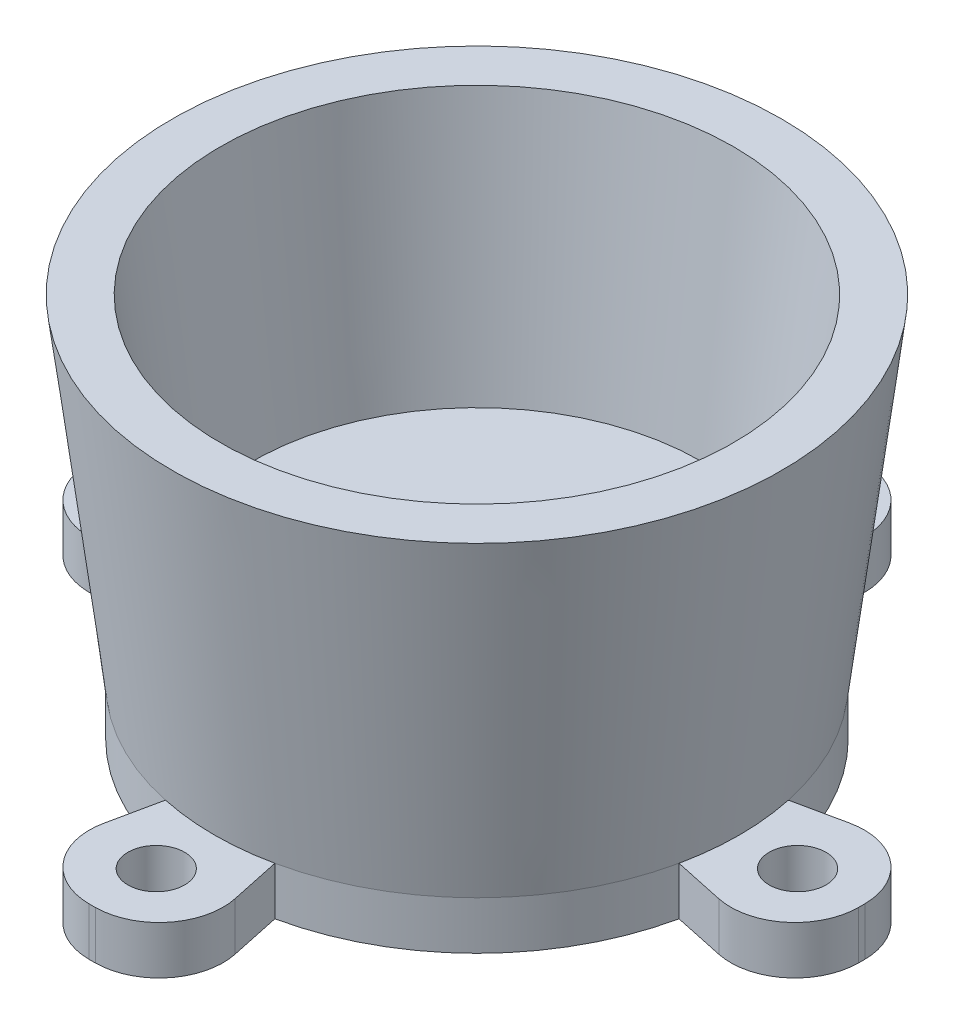
from build123d import *

# Parameters (mm, degrees)
SKETCH2_R          = 2.2479
CUT_EXTRUDE1_DEPTH = 4.81
FILLET1_R          = 5.08


with BuildPart() as part:
    # Sketch1 → Revolve1 (revolve)
    with BuildSketch(Plane.XY):
        Polygon((0, 0), (2.54, 20.32), (6.35, 20.32), (3.01625, -6.35), (12.7, -6.35), (12.7, -10.16), (0, -10.16), (0, -5.08), (-17.78, -5.08), (-17.78, 0), align=None)
    revolve(axis=Axis((-17.78, -37.211045685, 0), (0, 1, 0)))

    # Sketch2 → Cut-Extrude1 (cut, through all)
    with BuildSketch(Plane(origin=(0, -6.35, 0), x_dir=(1, 0, 0), z_dir=(0, 1, 0))):
        with Locations((-17.78, -25.4)):
            Circle(SKETCH2_R)
        with Locations((-17.78, 25.4)):
            Circle(SKETCH2_R)
        with Locations((-43.18, 0)):
            Circle(SKETCH2_R)
        with Locations((7.62, 0)):
            Circle(SKETCH2_R)
        with BuildLine():
            Line((12.03120427, -6.35), (2.559936246, -4.332552083))
            ThreePointArc((2.559936246, -4.332552083), (-3.074830602, -14.705169398), (-13.447447917, -20.339936246))
            Line((-13.447447917, -20.339936246), (-11.43, -29.81120427))
            ThreePointArc((-11.43, -29.81120427), (3.772614691, -21.552614691), (12.03120427, -6.35))
        make_face()
        with BuildLine():
            Line((-13.447447917, 20.339936246), (-11.43, 29.81120427))
            ThreePointArc((-11.43, 29.81120427), (3.772614691, 21.552614691), (12.03120427, 6.35))
            Line((12.03120427, 6.35), (2.559936246, 4.332552083))
            ThreePointArc((2.559936246, 4.332552083), (-3.074830602, 14.705169398), (-13.447447917, 20.339936246))
        make_face()
        with BuildLine():
            Line((-22.112552083, -20.339936246), (-24.13, -29.81120427))
            ThreePointArc((-24.13, -29.81120427), (-39.332614691, -21.552614691), (-47.59120427, -6.35))
            Line((-47.59120427, -6.35), (-38.119936246, -4.332552083))
            ThreePointArc((-38.119936246, -4.332552083), (-32.485169398, -14.705169398), (-22.112552083, -20.339936246))
        make_face()
        with BuildLine():
            Line((-47.59120427, 6.35), (-38.119936246, 4.332552083))
            ThreePointArc((-38.119936246, 4.332552083), (-32.485169398, 14.705169398), (-22.112552083, 20.339936246))
            Line((-22.112552083, 20.339936246), (-24.13, 29.81120427))
            ThreePointArc((-24.13, 29.81120427), (-39.332614691, 21.552614691), (-47.59120427, 6.35))
        make_face()
    extrude(amount=-CUT_EXTRUDE1_DEPTH, mode=Mode.SUBTRACT)

    # Fillet1
    fillet1_edges = [part.edges().sort_by_distance(p)[0] for p in [
        (-24.13, -8.255, 29.81120427),
        (-47.59120427, -8.255, 6.35),
        (-11.43, -8.255, -29.81120427),
        (12.03120427, -8.255, -6.35),
        (-47.59120427, -8.255, -6.35),
        (-24.13, -8.255, -29.81120427),
        (12.03120427, -8.255, 6.35),
        (-11.43, -8.255, 29.81120427),
    ]]
    fillet(fillet1_edges, radius=FILLET1_R)


solid = part.part
